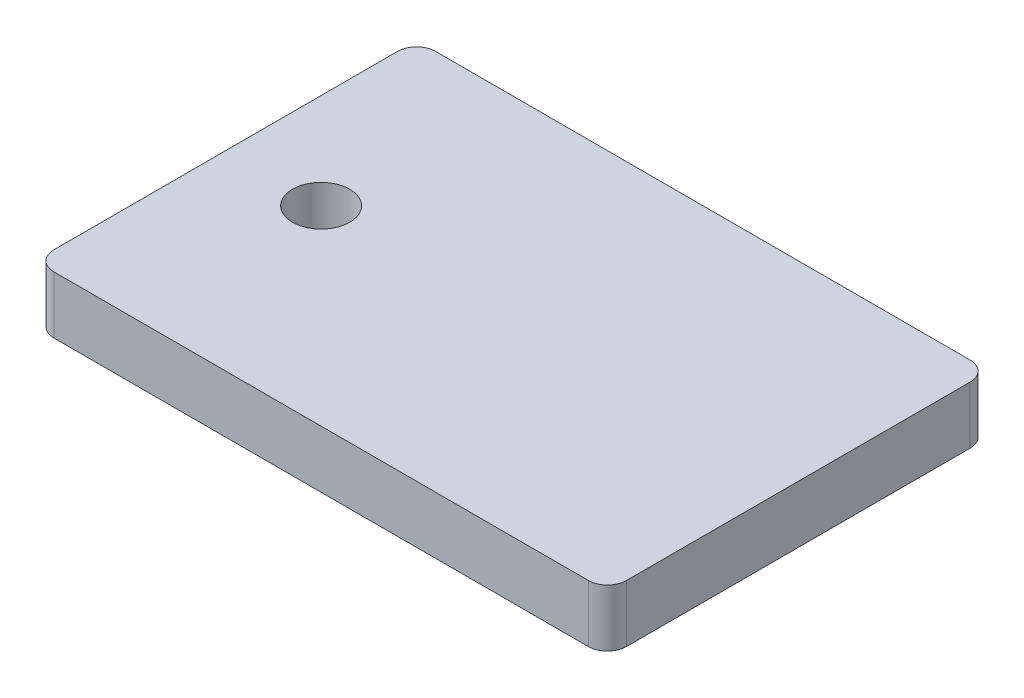
from build123d import *

# Parameters (mm, degrees)
SKETCH1_W           = 30
SKETCH1_H           = 20
SKETCH1_R           = 1.5
BOSS_EXTRUDE1_DEPTH = 3
FILLET1_R           = 1


with BuildPart() as part:
    # Sketch1 → Boss-Extrude1 (new body)
    with BuildSketch(Plane(origin=(0, 0, 0), x_dir=(1, 0, 0), z_dir=(0, 1, 0))):
        with Locations((15, 10)):
            Rectangle(SKETCH1_W, SKETCH1_H)
        with Locations((5, 10)):
            Circle(SKETCH1_R, mode=Mode.SUBTRACT)
    extrude(amount=BOSS_EXTRUDE1_DEPTH)

    # Fillet1
    fillet1_edges = [part.edges().sort_by_distance(p)[0] for p in [
        (0, 1.5, -20),
        (30, 1.5, -20),
        (30, 1.5, 0),
        (0, 1.5, 0),
    ]]
    fillet(fillet1_edges, radius=FILLET1_R)


solid = part.part
